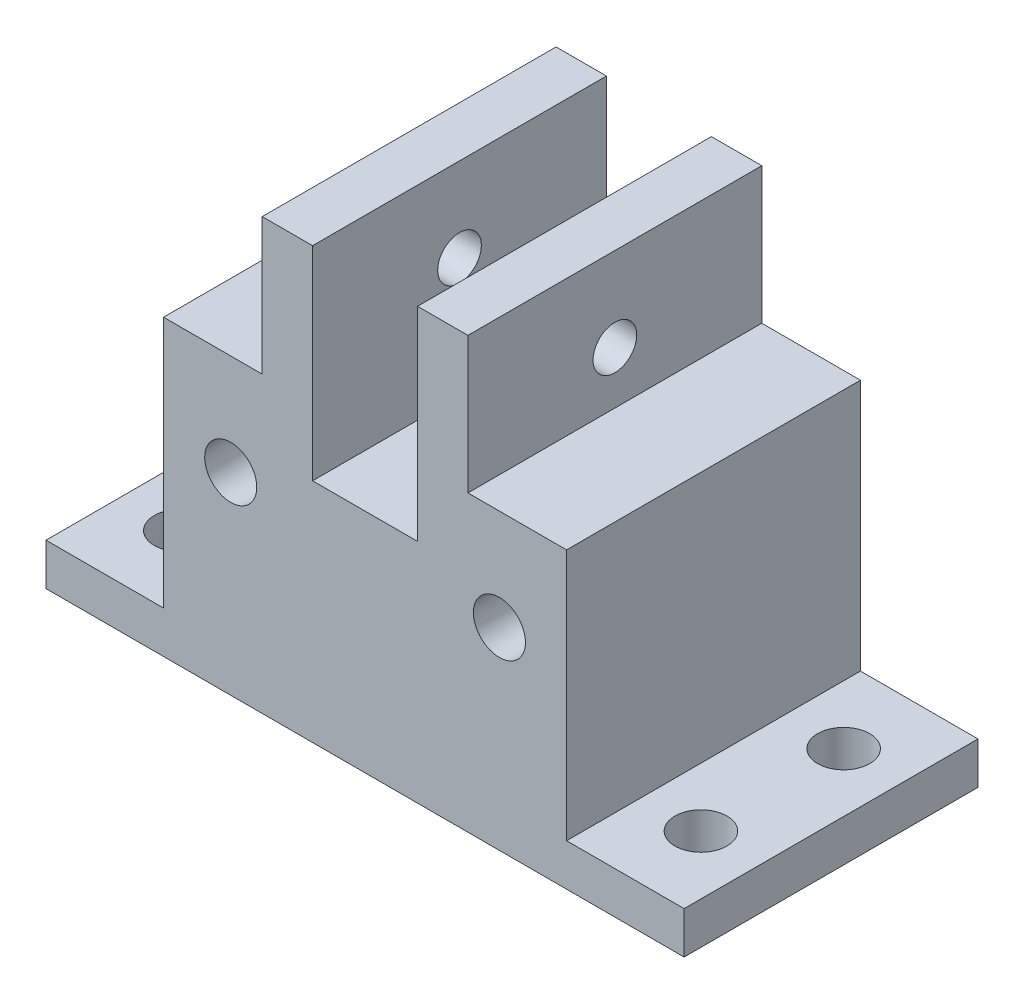
from build123d import *

# Parameters (mm, degrees)
SKETCH1_R           = 3.1
BOSS_EXTRUDE1_DEPTH = 35
SKETCH2_R           = 3.1
BOSS_EXTRUDE2_DEPTH = 5
BOSS_EXTRUDE3_DEPTH = 35
SKETCH4_R           = 2.6
CUT_EXTRUDE1_DEPTH  = 37.25
SKETCH6_W           = 12.5
SKETCH6_H           = 8
CUT_EXTRUDE2_DEPTH  = 36
SKETCH7_W           = 48
SKETCH7_H           = 35
BOSS_EXTRUDE4_DEPTH = 10
SKETCH8_W           = 14
SKETCH8_H           = 35
SKETCH8_R           = 3.1
BOSS_EXTRUDE5_DEPTH = 5


with BuildPart() as part:
    # Sketch1 → Boss-Extrude1 (new body)
    with BuildSketch(Plane.XY):
        Polygon((-5, -3.75), (-35, -3.75), (-35, -28.75), (13, -28.75), (13, -3.75), align=None)
        with Locations((5, -15.75)):
            Circle(SKETCH1_R, mode=Mode.SUBTRACT)
        with Locations((-27, -15.75)):
            Circle(SKETCH1_R, mode=Mode.SUBTRACT)
    extrude(amount=BOSS_EXTRUDE1_DEPTH)

    # Sketch2 → Boss-Extrude2 (add)
    with BuildSketch(Plane(origin=(0, 0, 0), x_dir=(-1, 0, 0), z_dir=(0, 0, -1))):
        with Locations((27, -15.75)):
            Circle(SKETCH2_R)
        with Locations((-5, -15.75)):
            Circle(SKETCH2_R)
    extrude(amount=-BOSS_EXTRUDE2_DEPTH)

    # Sketch3 → Boss-Extrude3 (add)
    with BuildSketch(Plane.XY.offset(35)):
        Polygon((-17.25, 2.5), (-17.25, -7.5), (-23.25, -7.5), (-23.25, 12.5), (-17.25, 12.5), align=None)
        Polygon((-4.75, 2.5), (-4.75, -7.5), (1.25, -7.5), (1.25, 12.5), (-4.75, 12.5), align=None)
    extrude(amount=-BOSS_EXTRUDE3_DEPTH)

    # Sketch4 → Cut-Extrude1 (cut, through all)
    with BuildSketch(Plane.ZY.offset(23.25)):
        with Locations((17.5, 2.5)):
            Circle(SKETCH4_R)
    extrude(amount=-CUT_EXTRUDE1_DEPTH, mode=Mode.SUBTRACT)

    # Sketch6 → Cut-Extrude2 (cut, through all)
    with BuildSketch(Plane.XY.offset(35)):
        with Locations((-11, -7.75)):
            Rectangle(SKETCH6_W, SKETCH6_H)
    extrude(amount=-CUT_EXTRUDE2_DEPTH, mode=Mode.SUBTRACT)

    # Sketch7 → Boss-Extrude4 (add)
    with BuildSketch(Plane.XZ.offset(28.75)):
        with Locations((-11, 17.5)):
            Rectangle(SKETCH7_W, SKETCH7_H)
    extrude(amount=BOSS_EXTRUDE4_DEPTH)

    # Sketch8 → Boss-Extrude5 (add)
    with BuildSketch(Plane.XZ.offset(38.75)):
        with Locations((-42, 17.5)):
            Rectangle(SKETCH8_W, SKETCH8_H)
        with Locations((-42, 9)):
            Circle(SKETCH8_R, mode=Mode.SUBTRACT)
        with Locations((-42, 26)):
            Circle(SKETCH8_R, mode=Mode.SUBTRACT)
        with Locations((20, 17.5)):
            Rectangle(SKETCH8_W, SKETCH8_H)
        with Locations((20, 9)):
            Circle(SKETCH8_R, mode=Mode.SUBTRACT)
        with Locations((20, 26)):
            Circle(SKETCH8_R, mode=Mode.SUBTRACT)
    extrude(amount=-BOSS_EXTRUDE5_DEPTH)


solid = part.part
